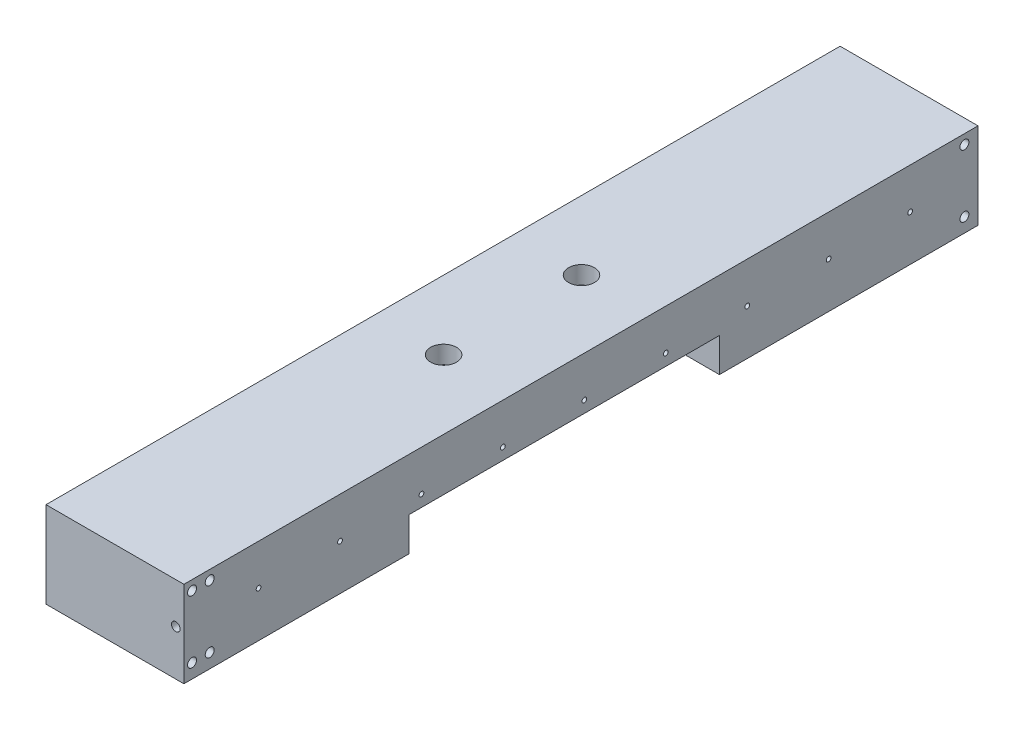
from build123d import *

# Parameters (mm, degrees)
SKETCH1_W           = 101.6
SKETCH1_H           = 63.5
BOSS_EXTRUDE1_DEPTH = 585.0001
SKETCH2_W           = 228.6
SKETCH2_H           = 25
CUT_EXTRUDE1_DEPTH  = 102.6
CUT_EXTRUDE4_START  = -101.6
CUT_EXTRUDE4_DEPTH  = 6.35
CUT_EXTRUDE5_START  = -101.6
CUT_EXTRUDE5_DEPTH  = 25.4
SKETCH6_R           = 4.934351916
CUT_EXTRUDE6_DEPTH  = 39.5
CUT_EXTRUDE7_DEPTH  = 12.7
SKETCH8_R           = 3.175
CUT_EXTRUDE8_DEPTH  = 12.7
CUT_EXTRUDE10_START = 50.8
SKETCH10_R          = 9.525
CUT_EXTRUDE10_DEPTH = 14.1


with BuildPart() as part:
    # Sketch1 → Boss-Extrude1 (new body)
    with BuildSketch(Plane.XY):
        with Locations((50.8, 31.75)):
            Rectangle(SKETCH1_W, SKETCH1_H)
    extrude(amount=BOSS_EXTRUDE1_DEPTH)

    # Sketch2 → Cut-Extrude1 (cut, through all)
    with BuildSketch(Plane.ZY):
        with Locations((304.8, 12.5)):
            Rectangle(SKETCH2_W, SKETCH2_H)
    extrude(amount=-CUT_EXTRUDE1_DEPTH, mode=Mode.SUBTRACT)

    # Sketch5 → Cut-Extrude4 (cut)
    with BuildSketch(Plane.ZY.offset(CUT_EXTRUDE4_START)):
        with BuildLine():
            ThreePointArc((170, 35.25), (168.25, 33.5), (170, 31.75))
            ThreePointArc((170, 31.75), (171.75, 33.5), (170, 35.25))
        make_face()
        with BuildLine():
            ThreePointArc((110, 31.75), (111.75, 33.5), (110, 35.25))
            ThreePointArc((110, 35.25), (108.25, 33.5), (110, 31.75))
        make_face()
        with BuildLine():
            ThreePointArc((50, 31.75), (51.75, 33.5), (50, 35.25))
            ThreePointArc((50, 35.25), (48.25, 33.5), (50, 31.75))
        make_face()
        with BuildLine():
            ThreePointArc((530, 31.75), (531.75, 33.5), (530, 35.25))
            ThreePointArc((530, 35.25), (528.25, 33.5), (530, 31.75))
        make_face()
        with BuildLine():
            ThreePointArc((470, 31.75), (471.75, 33.5), (470, 35.25))
            ThreePointArc((470, 35.25), (468.25, 33.5), (470, 31.75))
        make_face()
        with BuildLine():
            ThreePointArc((410, 31.75), (411.75, 33.5), (410, 35.25))
            ThreePointArc((410, 35.25), (408.25, 33.5), (410, 31.75))
        make_face()
        with BuildLine():
            ThreePointArc((350, 31.75), (351.75, 33.5), (350, 35.25))
            ThreePointArc((350, 35.25), (348.25, 33.5), (350, 31.75))
        make_face()
        with BuildLine():
            ThreePointArc((290, 31.75), (291.75, 33.5), (290, 35.25))
            ThreePointArc((290, 35.25), (288.25, 33.5), (290, 31.75))
        make_face()
        with BuildLine():
            ThreePointArc((230, 31.75), (231.75, 33.5), (230, 35.25))
            ThreePointArc((230, 35.25), (228.25, 33.5), (230, 31.75))
        make_face()
    extrude(amount=CUT_EXTRUDE4_DEPTH, mode=Mode.SUBTRACT)

    # Sketch5_3 → Cut-Extrude5 (cut)
    with BuildSketch(Plane.ZY.offset(CUT_EXTRUDE5_START)):
        with BuildLine():
            ThreePointArc((562.7, 10.5), (566, 7.2), (569.3, 10.5))
            ThreePointArc((569.3, 10.5), (566, 13.8), (562.7, 10.5))
        make_face()
        with BuildLine():
            ThreePointArc((582.3, 10.5), (579, 13.8), (575.7, 10.5))
            ThreePointArc((575.7, 10.5), (579, 7.2), (582.3, 10.5))
        make_face()
        with BuildLine():
            ThreePointArc((575.7, 56.5), (579, 53.2), (582.3, 56.5))
            ThreePointArc((582.3, 56.5), (579, 59.8), (575.7, 56.5))
        make_face()
        with BuildLine():
            ThreePointArc((562.7, 56.5), (566, 53.2), (569.3, 56.5))
            ThreePointArc((569.3, 56.5), (566, 59.8), (562.7, 56.5))
        make_face()
        with BuildLine():
            ThreePointArc((6.7, 10.5), (10, 7.2), (13.3, 10.5))
            ThreePointArc((13.3, 10.5), (10, 13.8), (6.7, 10.5))
        make_face()
        with BuildLine():
            ThreePointArc((6.7, 56.5), (10, 53.2), (13.3, 56.5))
            ThreePointArc((13.3, 56.5), (10, 59.8), (6.7, 56.5))
        make_face()
    extrude(amount=CUT_EXTRUDE5_DEPTH, mode=Mode.SUBTRACT)

    # Sketch6 → Cut-Extrude6 (cut, through all)
    with BuildSketch(Plane.XZ.offset(-25)):
        with Locations((50.8, 342.9)):
            Circle(SKETCH6_R)
        with Locations((50.8, 241.3)):
            Circle(SKETCH6_R)
    extrude(amount=-CUT_EXTRUDE6_DEPTH, mode=Mode.SUBTRACT)

    # Sketch7 → Cut-Extrude7 (cut)
    with BuildSketch(Plane.ZY):
        with BuildLine():
            ThreePointArc((525.637642589, 39.694194493), (528.38398287, 38.11238), (531.130323151, 39.694194493))
            ThreePointArc((531.130323151, 39.694194493), (531.55898287, 41.28738), (531.130323151, 42.880565507))
            ThreePointArc((531.130323151, 42.880565507), (528.38398287, 44.46238), (525.637642589, 42.880565507))
            ThreePointArc((525.637642589, 42.880565507), (525.20898287, 41.28738), (525.637642589, 39.694194493))
        make_face()
        with BuildLine():
            ThreePointArc((53.548542941, 42.880565507), (50.80220266, 44.46238), (48.055862379, 42.880565507))
            ThreePointArc((48.055862379, 42.880565507), (47.62720266, 41.28738), (48.055862379, 39.694194493))
            ThreePointArc((48.055862379, 39.694194493), (50.80220266, 38.11238), (53.548542941, 39.694194493))
            ThreePointArc((53.548542941, 39.694194493), (53.97720266, 41.28738), (53.548542941, 42.880565507))
        make_face()
    extrude(amount=-CUT_EXTRUDE7_DEPTH, mode=Mode.SUBTRACT)

    # Sketch8 → Cut-Extrude8 (cut)
    with BuildSketch(Plane.XY.offset(585.0001)):
        with Locations((95.65, 33.5)):
            Circle(SKETCH8_R)
    extrude(amount=-CUT_EXTRUDE8_DEPTH, mode=Mode.SUBTRACT)

    # Sketch10 → Cut-Extrude10 (cut, through all)
    with BuildSketch(Plane(origin=(0, -0.4, 0), x_dir=(1, 0, 0), z_dir=(0, 1, 0)).offset(CUT_EXTRUDE10_START)):
        with Locations((50.8, -342.9)):
            Circle(SKETCH10_R)
        with Locations((50.8, -241.3)):
            Circle(SKETCH10_R)
    extrude(amount=CUT_EXTRUDE10_DEPTH, mode=Mode.SUBTRACT)


solid = part.part
